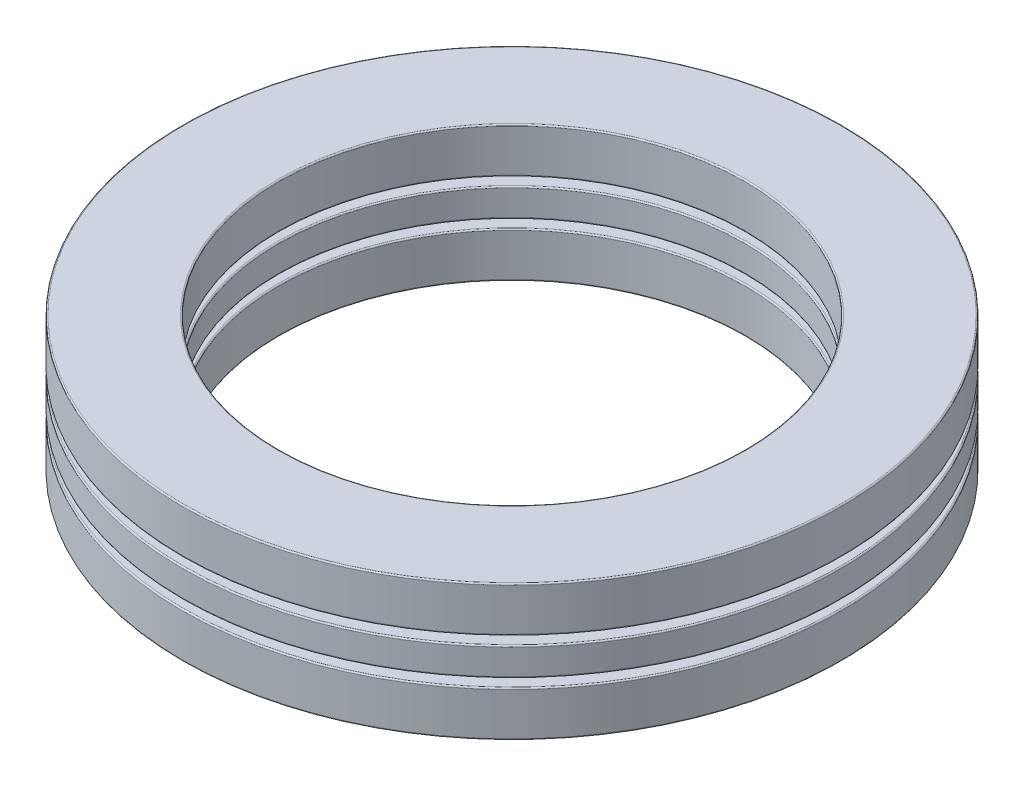
from build123d import *

# Parameters (mm, degrees)
SKETCH1_W         = 7.8994
SKETCH1_H         = 2.312458334
CIRPATTERN1_COUNT = 11
CIRPATTERN1_ANGLE = 327.272727273
CIRPATTERN2_COUNT = 11
SKETCH4_W         = 7.8994
SKETCH4_H         = 3.699933333
FILLET1_R         = 0.110998
FILLET2_R         = 0.110998
FILLET3_R         = 0.110998


with BuildPart() as part:
    # Sketch1 → Revolve1 (revolve)
    with BuildSketch(Plane(origin=(0, 0, 0), x_dir=(0, 0, -1), z_dir=(1, 0, 0))):
        with Locations((-23.0378, 0)):
            Rectangle(SKETCH1_W, SKETCH1_H)
    revolve(axis=Axis((0, -5.5499, 0), (0, 1, 0)))

    # Sketch3 → Cut-Revolve1 (revolve, cut)
    with BuildSketch(Plane(origin=(0, 0, 0), x_dir=(0, 0, -1), z_dir=(1, 0, 0))):
        with BuildLine():
            Line((-23.0378, 1.849966667), (-23.0378, -1.849966667))
            ThreePointArc((-23.0378, -1.849966667), (-24.887766667, 0), (-23.0378, 1.849966667))
        make_face()
    cut_revolve1 = revolve(axis=Axis((0, 1.849966667, 23.0378), (0, -1, 0)), mode=Mode.SUBTRACT)

    # CirPattern2: Cut-Revolve1 ×11 about axis
    cirpattern2_axis = Axis((0, 0, 0), (0, 1, 0))
    for i in range(1, CIRPATTERN2_COUNT):
        add(cut_revolve1.rotate(cirpattern2_axis, i * 360 / CIRPATTERN2_COUNT), mode=Mode.SUBTRACT)

    # Fillet2
    fillet2_edges = [part.edges().sort_by_distance(p)[0] for p in [
        (0, 1.156229167, -26.9875),
        (0, 1.156229167, -19.0881),
        (0, -1.156229167, -19.0881),
        (0, -1.156229167, -26.9875),
    ]]
    fillet(fillet2_edges, radius=FILLET2_R)


with BuildPart() as body_2:
    # Sketch2 → Revolve2 (revolve)
    with BuildSketch(Plane(origin=(0, 0, 0), x_dir=(0, 0, -1), z_dir=(1, 0, 0))):
        with BuildLine():
            Line((-23.0378, 1.849966667), (-23.0378, -1.849966667))
            ThreePointArc((-23.0378, -1.849966667), (-24.887766667, 0), (-23.0378, 1.849966667))
        make_face()
    revolve(axis=Axis((0, 1.849966667, 23.0378), (0, -1, 0)))


with BuildPart() as cirpattern1_1:
    # CirPattern1: pattern copy
    add(body_2.part.rotate(Axis((0, 5.5499, 0), (0, -1, 0)), 1 * CIRPATTERN1_ANGLE / (CIRPATTERN1_COUNT - 1)))


with BuildPart() as cirpattern1_2:
    # CirPattern1: pattern copy
    add(body_2.part.rotate(Axis((0, 5.5499, 0), (0, -1, 0)), 2 * CIRPATTERN1_ANGLE / (CIRPATTERN1_COUNT - 1)))


with BuildPart() as cirpattern1_3:
    # CirPattern1: pattern copy
    add(body_2.part.rotate(Axis((0, 5.5499, 0), (0, -1, 0)), 3 * CIRPATTERN1_ANGLE / (CIRPATTERN1_COUNT - 1)))


with BuildPart() as cirpattern1_4:
    # CirPattern1: pattern copy
    add(body_2.part.rotate(Axis((0, 5.5499, 0), (0, -1, 0)), 4 * CIRPATTERN1_ANGLE / (CIRPATTERN1_COUNT - 1)))


with BuildPart() as cirpattern1_5:
    # CirPattern1: pattern copy
    add(body_2.part.rotate(Axis((0, 5.5499, 0), (0, -1, 0)), 5 * CIRPATTERN1_ANGLE / (CIRPATTERN1_COUNT - 1)))


with BuildPart() as cirpattern1_6:
    # CirPattern1: pattern copy
    add(body_2.part.rotate(Axis((0, 5.5499, 0), (0, -1, 0)), 6 * CIRPATTERN1_ANGLE / (CIRPATTERN1_COUNT - 1)))


with BuildPart() as cirpattern1_7:
    # CirPattern1: pattern copy
    add(body_2.part.rotate(Axis((0, 5.5499, 0), (0, -1, 0)), 7 * CIRPATTERN1_ANGLE / (CIRPATTERN1_COUNT - 1)))


with BuildPart() as cirpattern1_8:
    # CirPattern1: pattern copy
    add(body_2.part.rotate(Axis((0, 5.5499, 0), (0, -1, 0)), 8 * CIRPATTERN1_ANGLE / (CIRPATTERN1_COUNT - 1)))


with BuildPart() as cirpattern1_9:
    # CirPattern1: pattern copy
    add(body_2.part.rotate(Axis((0, 5.5499, 0), (0, -1, 0)), 9 * CIRPATTERN1_ANGLE / (CIRPATTERN1_COUNT - 1)))


with BuildPart() as cirpattern1_10:
    # CirPattern1: pattern copy
    add(body_2.part.rotate(Axis((0, 5.5499, 0), (0, -1, 0)), 10 * CIRPATTERN1_ANGLE / (CIRPATTERN1_COUNT - 1)))


with BuildPart() as body_13:
    # Sketch4 → Revolve3 (revolve)
    with BuildSketch(Plane(origin=(0, 0, 0), x_dir=(0, 0, -1), z_dir=(1, 0, 0))):
        with Locations((-23.0378, 3.699933334)):
            Rectangle(SKETCH4_W, SKETCH4_H)
        with Locations((-23.0378, -3.699933334)):
            Rectangle(SKETCH4_W, SKETCH4_H)
    revolve(axis=Axis((0, -5.5499, 0), (0, 1, 0)))

    # Fillet1
    fillet1_edges = [body_13.edges().sort_by_distance(p)[0] for p in [
        (0, 1.849966667, -26.9875),
        (0, 1.849966667, -19.0881),
        (0, 5.5499, -19.0881),
        (0, 5.5499, -26.9875),
    ]]
    fillet(fillet1_edges, radius=FILLET1_R)

    # Fillet3
    fillet3_edges = [body_13.edges().sort_by_distance(p)[0] for p in [
        (0, -5.5499, -26.9875),
        (0, -5.5499, -19.0881),
        (0, -1.849966667, -19.0881),
        (0, -1.849966667, -26.9875),
    ]]
    fillet(fillet3_edges, radius=FILLET3_R)


solid = Compound([part.part, body_2.part, cirpattern1_1.part, cirpattern1_2.part, cirpattern1_3.part, cirpattern1_4.part, cirpattern1_5.part, cirpattern1_6.part, cirpattern1_7.part, cirpattern1_8.part, cirpattern1_9.part, cirpattern1_10.part, body_13.part])
